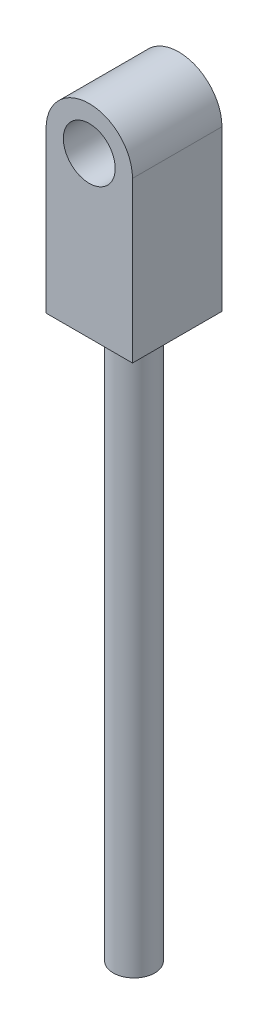
from build123d import *

# Parameters (mm, degrees)
SKETCH1_R                = 1.5
BOSS_EXTRUDE1_DEPTH      = 1.725
BOSS_EXTRUDE1_DEPTH_BACK = 3.45
SKETCH2_R                = 1.203
BOSS_EXTRUDE2_DEPTH      = 32.5


with BuildPart() as part:
    # Sketch1 → Boss-Extrude1 (new body, two sides)
    with BuildSketch(Plane.XY) as boss_extrude1_sk:
        with BuildLine():
            Line((-2.5, 0), (-2.5, -9.25))
            Line((-2.5, -9.25), (2.5, -9.25))
            Line((2.5, -9.25), (2.5, 0))
            ThreePointArc((2.5, 0), (0, 2.5), (-2.5, 0))
        make_face()
        Circle(SKETCH1_R, mode=Mode.SUBTRACT)
    extrude(amount=BOSS_EXTRUDE1_DEPTH)
    extrude(boss_extrude1_sk.sketch, amount=-BOSS_EXTRUDE1_DEPTH_BACK)

    # Sketch2 → Boss-Extrude2 (add)
    with BuildSketch(Plane.XZ.offset(9.25)):
        with Locations((0, -0.8625)):
            Circle(SKETCH2_R)
    extrude(amount=BOSS_EXTRUDE2_DEPTH)


solid = part.part
